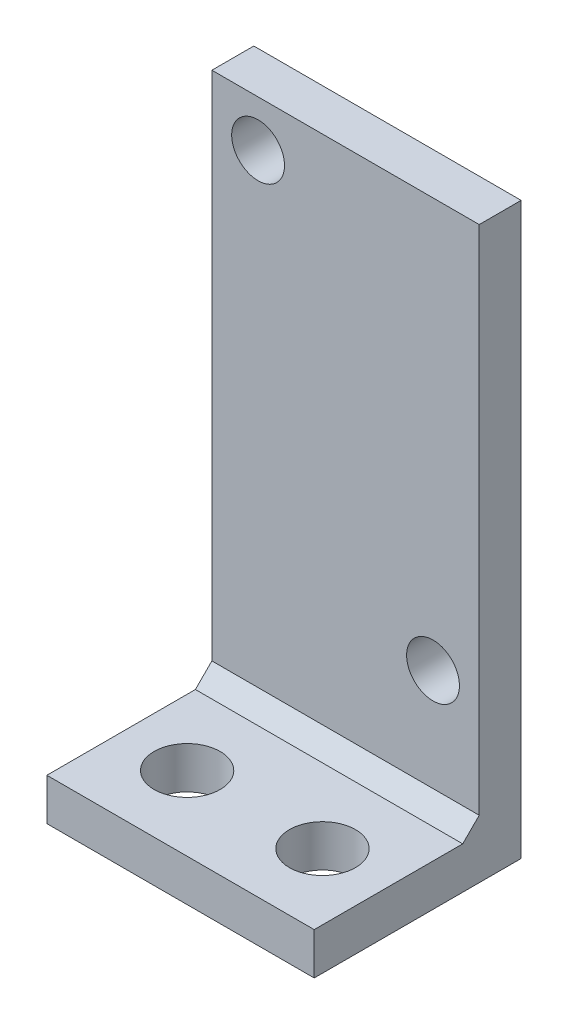
from build123d import *

# Parameters (mm, degrees)
SKETCH1_W           = 16.2
SKETCH1_H           = 34.54
BOSS_EXTRUDE1_DEPTH = 2.54
SKETCH2_W           = 16.2
SKETCH2_H           = 2.54
BOSS_EXTRUDE2_DEPTH = 10
CHAMFER1_SIZE       = 1
SKETCH4_R           = 1.6
CUT_EXTRUDE1_DEPTH  = 2.54
SKETCH5_R           = 2
CUT_EXTRUDE2_DEPTH  = 3.54


with BuildPart() as part:
    # Sketch1 → Boss-Extrude1 (new body)
    with BuildSketch(Plane.XY):
        with Locations((8.1, 17.27)):
            Rectangle(SKETCH1_W, SKETCH1_H)
    extrude(amount=BOSS_EXTRUDE1_DEPTH)

    # Sketch2 → Boss-Extrude2 (add)
    with BuildSketch(Plane.XY.offset(2.54)):
        with Locations((8.1, 1.27)):
            Rectangle(SKETCH2_W, SKETCH2_H)
    extrude(amount=BOSS_EXTRUDE2_DEPTH)

    # Chamfer1
    chamfer1_edges = [part.edges().sort_by_distance(p)[0] for p in [
        (8.1, 2.54, 2.54),
    ]]
    chamfer(chamfer1_edges, length=CHAMFER1_SIZE)

    # Sketch4 → Cut-Extrude1 (cut)
    with BuildSketch(Plane(origin=(0, 0, 0), x_dir=(-1, 0, 0), z_dir=(0, 0, -1))):
        with Locations((-13.4, 9.74)):
            Circle(SKETCH4_R)
        with Locations((-2.8, 31.74)):
            Circle(SKETCH4_R)
    extrude(amount=-CUT_EXTRUDE1_DEPTH, mode=Mode.SUBTRACT)

    # Sketch5 → Cut-Extrude2 (cut, through all)
    with BuildSketch(Plane(origin=(0, 2.54, 0), x_dir=(1, 0, 0), z_dir=(0, 1, 0))):
        with Locations((12.2, -8.04)):
            Circle(SKETCH5_R)
        with Locations((4, -8.04)):
            Circle(SKETCH5_R)
    extrude(amount=-CUT_EXTRUDE2_DEPTH, mode=Mode.SUBTRACT)


solid = part.part
